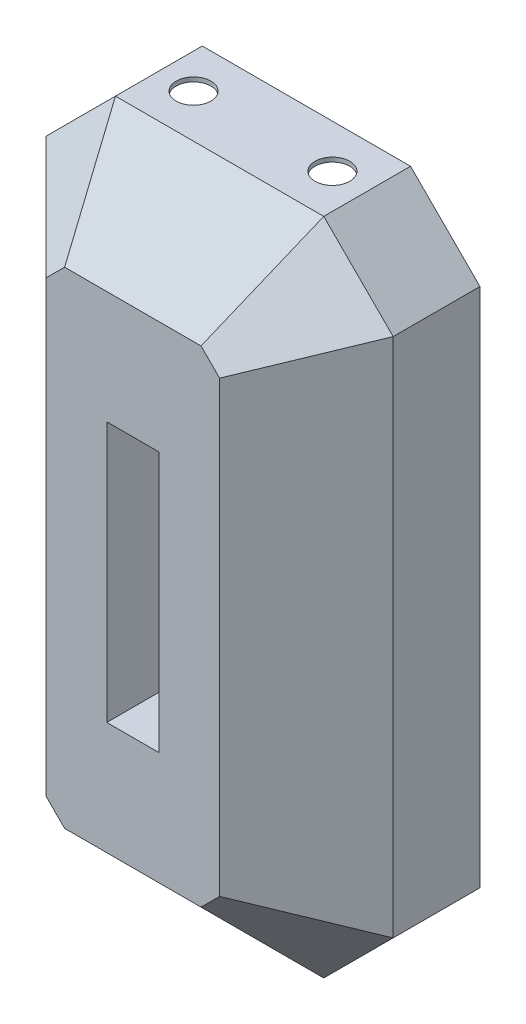
from build123d import *

# Parameters (mm, degrees)
BOSS_EXTRUDE1_DEPTH = 127
SKETCH5_W           = 76.2
SKETCH5_H           = 381
CUT_EXTRUDE1_DEPTH  = 255
SKETCH6_R           = 25.4
CUT_EXTRUDE2_DEPTH  = 6.35


with BuildPart() as part:
    # Sketch1 → Boss-Extrude1 (new body)
    with BuildSketch(Plane.XY):
        Polygon((-152.4, 482.6), (-254, 381), (-254, -381), (-152.4, -482.6), (152.4, -482.6), (254, -381), (254, 381), (152.4, 482.6), align=None)
        Polygon((-149.769743879, 476.25), (-247.65, 378.369743879), (-247.65, -378.369743879), (-149.769743879, -476.25), (149.769743879, -476.25), (247.65, -378.369743879), (247.65, 378.369743879), (149.769743879, 476.25), align=None, mode=Mode.SUBTRACT)
    extrude(amount=BOSS_EXTRUDE1_DEPTH)

    # Sketch6 → Cut-Extrude2 (cut)
    with BuildSketch(Plane(origin=(0, 482.6, 0), x_dir=(1, 0, 0), z_dir=(0, 1, 0))):
        with Locations((101.6, -63.5)):
            Circle(SKETCH6_R)
        with Locations((-101.6, -63.5)):
            Circle(SKETCH6_R)
    extrude(amount=-CUT_EXTRUDE2_DEPTH, mode=Mode.SUBTRACT)


with BuildPart() as body_2:
    # Sketch3 → Loft3 section 0
    with BuildSketch(Plane.XY.offset(127)):
        Polygon((-152.4, 482.6), (152.4, 482.6), (254, 381), (254, -381), (152.4, -482.6), (-152.4, -482.6), (-254, -381), (-254, 381), align=None)
    # Sketch4 → Loft3 section 1
    with BuildSketch(Plane.XY.offset(254)):
        Polygon((-127, 328.394877579), (-99.794877579, 355.6), (99.794877579, 355.6), (127, 328.394877579), (127, -328.394877579), (99.794877579, -355.6), (-99.794877579, -355.6), (-127, -328.394877579), align=None)
    loft()

    # Sketch5 → Cut-Extrude1 (cut, through all)
    with BuildSketch(Plane.XY.offset(254)):
        Rectangle(SKETCH5_W, SKETCH5_H)
    extrude(amount=-CUT_EXTRUDE1_DEPTH, mode=Mode.SUBTRACT)


solid = Compound([part.part, body_2.part])
